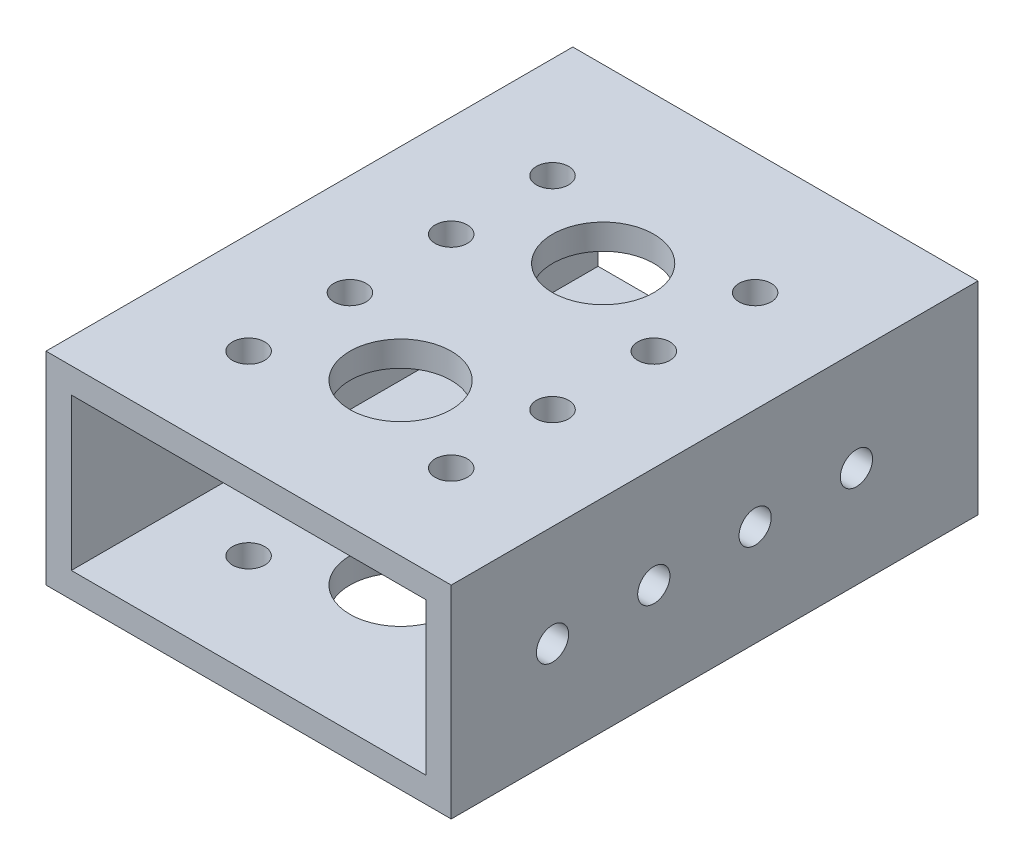
from build123d import *

# Parameters (mm, degrees)
SKETCH1_W           = 50.8
SKETCH1_H           = 25.4
SKETCH1_W_2         = 44.45
SKETCH1_H_2         = 19.05
BOSS_EXTRUDE1_DEPTH = 66.04
SKETCH2_R           = 2.0193
SKETCH2_R_2         = 6.35
CUT_EXTRUDE1_DEPTH  = 63.5
SKETCH3_R           = 2.0193
CUT_EXTRUDE2_DEPTH  = 63.5


with BuildPart() as part:
    # Sketch1 → Boss-Extrude1 (new body)
    with BuildSketch(Plane.XY):
        with Locations((25.4, 12.7)):
            Rectangle(SKETCH1_W, SKETCH1_H)
        with Locations((25.4, 12.7)):
            Rectangle(SKETCH1_W_2, SKETCH1_H_2, mode=Mode.SUBTRACT)
    extrude(amount=BOSS_EXTRUDE1_DEPTH)

    # Sketch2 → Cut-Extrude1 (cut)
    with BuildSketch(Plane(origin=(0, 25.4, 0), x_dir=(1, 0, 0), z_dir=(0, 1, 0))):
        with Locations((12.7, -53.34)):
            Circle(SKETCH2_R)
        with Locations((25.4, -46.99)):
            Circle(SKETCH2_R_2)
        with Locations((38.1, -53.34)):
            Circle(SKETCH2_R)
        with Locations((12.7, -40.64)):
            Circle(SKETCH2_R)
        with Locations((38.1, -40.64)):
            Circle(SKETCH2_R)
        with Locations((12.7, -27.94)):
            Circle(SKETCH2_R)
        with Locations((38.1, -27.94)):
            Circle(SKETCH2_R)
        with Locations((12.7, -15.24)):
            Circle(SKETCH2_R)
        with Locations((38.1, -15.24)):
            Circle(SKETCH2_R)
        with Locations((25.4, -21.59)):
            Circle(SKETCH2_R_2)
    extrude(amount=-CUT_EXTRUDE1_DEPTH, mode=Mode.SUBTRACT)

    # Sketch3 → Cut-Extrude2 (cut)
    with BuildSketch(Plane(origin=(50.8, 0, 0), x_dir=(0, 0, -1), z_dir=(1, 0, 0))):
        with Locations((-53.34, 12.7)):
            Circle(SKETCH3_R)
        with Locations((-40.64, 12.7)):
            Circle(SKETCH3_R)
        with Locations((-27.94, 12.7)):
            Circle(SKETCH3_R)
        with Locations((-15.24, 12.7)):
            Circle(SKETCH3_R)
    extrude(amount=-CUT_EXTRUDE2_DEPTH, mode=Mode.SUBTRACT)


solid = part.part
